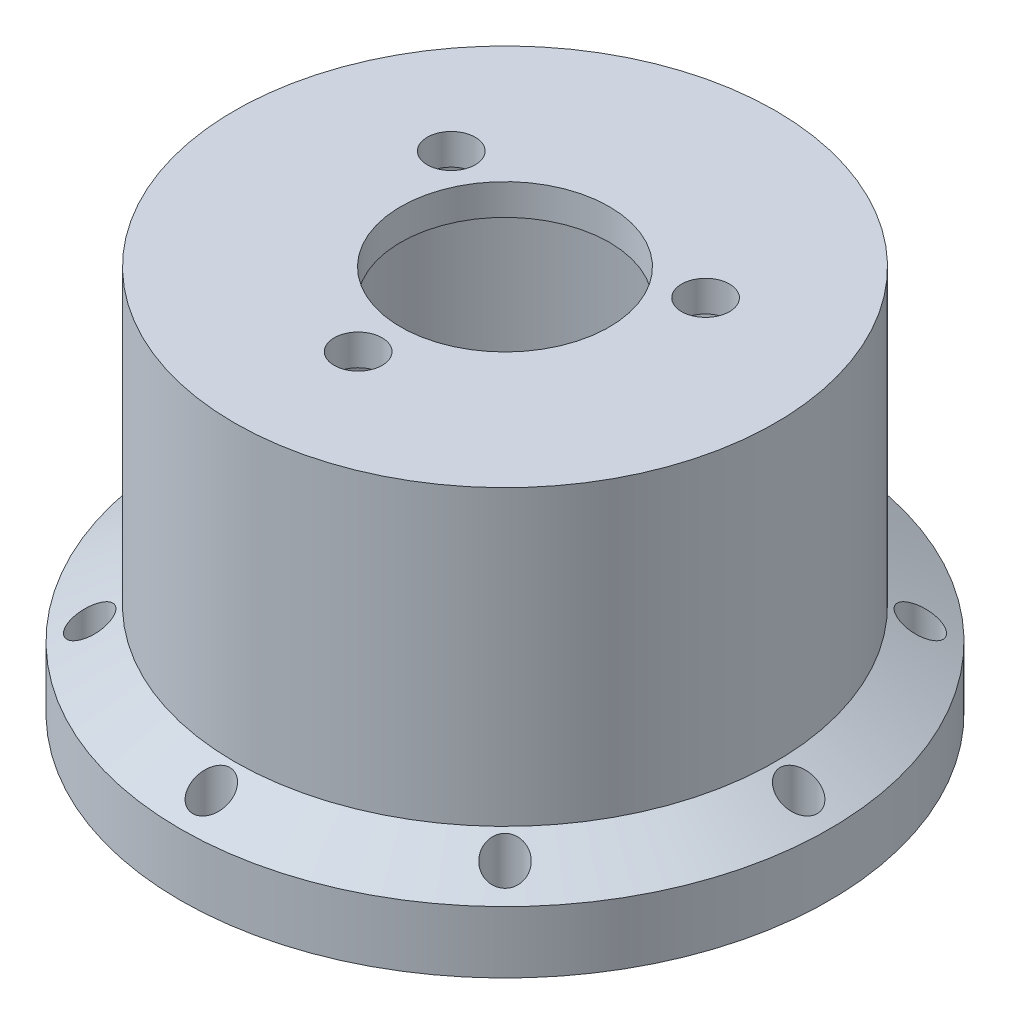
from build123d import *

# Parameters (mm, degrees)
SKETCH_2_R               = 1.2
CUT_EXTRUDE_1_DEPTH      = 8
PATTERN_CIRCULAR_1_COUNT = 8
SKETCH_3_R               = 1.55
CUT_EXTRUDE_2_DEPTH      = 10


with BuildPart() as part:
    # 草图1 → 旋转1 (revolve)
    with BuildSketch(Plane.XY):
        Polygon((-16, 0), (-17, 0), (-17, 2), (-21, 2), (-21, 6), (-17.5, 8.020725942), (-17.5, 27), (-6.75, 27), (-6.75, 25), (-16, 25), align=None)
    revolve(axis=Axis((0, 0, 0), (0, 1, 0)))

    # 草图2 → 切除-拉伸1 (cut)
    with BuildSketch(Plane.XZ.offset(-2)):
        with Locations((0, -19)):
            Circle(SKETCH_2_R)
    cut_extrude_1 = extrude(amount=-CUT_EXTRUDE_1_DEPTH, mode=Mode.SUBTRACT)

    # 阵列(圆周)1: 切除-拉伸1 ×8 about axis
    pattern_circular_1_axis = Axis((0, 0, 0), (0, 1, 0))
    for i in range(1, PATTERN_CIRCULAR_1_COUNT):
        add(cut_extrude_1.rotate(pattern_circular_1_axis, i * 360 / PATTERN_CIRCULAR_1_COUNT), mode=Mode.SUBTRACT)

    # 草图3 → 切除-拉伸2 (cut)
    with BuildSketch(Plane(origin=(0, 27, 0), x_dir=(1, 0, 0), z_dir=(0, 1, 0))):
        with Locations((0, -9.5)):
            Circle(SKETCH_3_R)
        with Locations((-8.227241336, 4.75)):
            Circle(SKETCH_3_R)
        with Locations((8.227241336, 4.75)):
            Circle(SKETCH_3_R)
    extrude(amount=-CUT_EXTRUDE_2_DEPTH, mode=Mode.SUBTRACT)


solid = part.part
